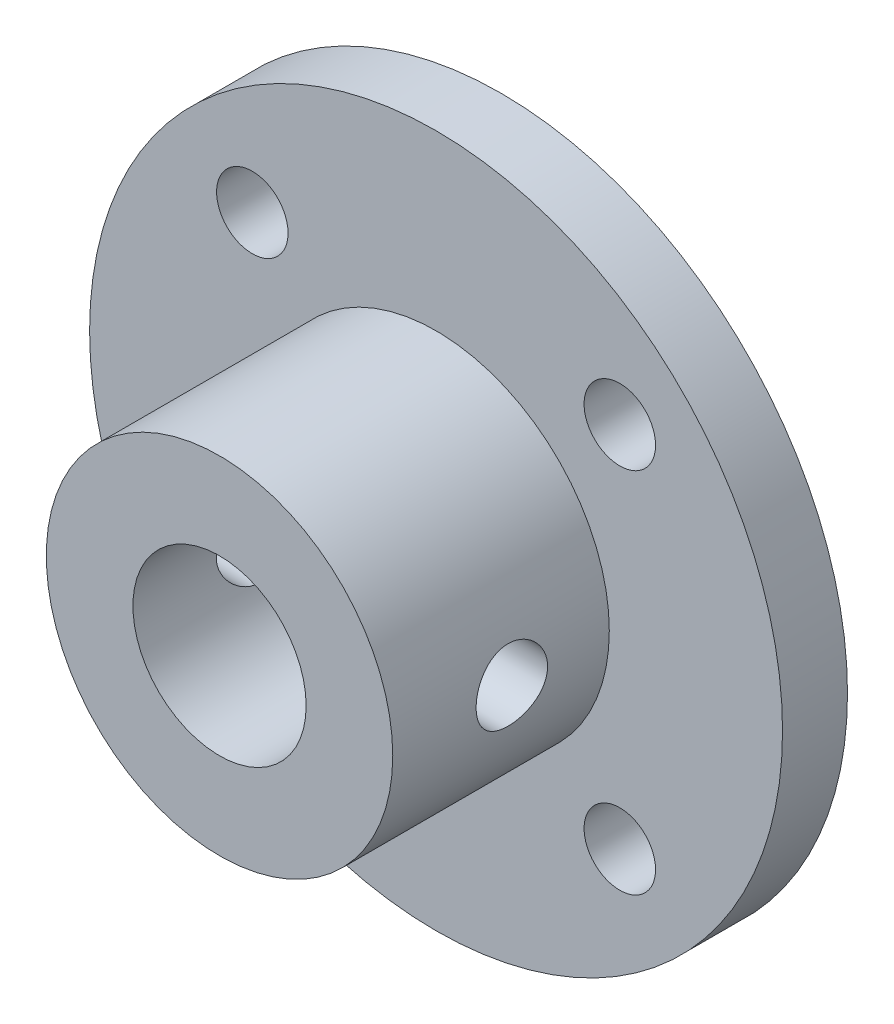
from build123d import *

# Parameters (mm, degrees)
SKETCH_1_R             = 16
EXTRUDE_1_DEPTH        = 3
SKETCH_2_R             = 8
EXTRUDE_2_DEPTH        = 10
SKETCH_3_R             = 4
CUT_EXTRUDE_1_DEPTH    = 14
SKETCH_5_R             = 1.5
CUT_EXTRUDE_3_DEPTH    = 4
HOLE_WIZARD_M4_1_D     = 3.3
HOLE_WIZARD_M4_1_DEPTH = 3
HOLE_WIZARD_M4_2_D     = 3.3


with BuildPart() as part:
    # 草图1 → 凸台-拉伸1 (new body)
    with BuildSketch(Plane.XY):
        Circle(SKETCH_1_R)
    extrude(amount=EXTRUDE_1_DEPTH)

    # 草图2 → 凸台-拉伸2 (add)
    with BuildSketch(Plane.XY.offset(3)):
        Circle(SKETCH_2_R)
    extrude(amount=EXTRUDE_2_DEPTH)

    # 草图3 → 切除-拉伸1 (cut, through all)
    with BuildSketch(Plane.XY.offset(13)):
        Circle(SKETCH_3_R)
    extrude(amount=-CUT_EXTRUDE_1_DEPTH, mode=Mode.SUBTRACT)

    # 草图5 → 切除-拉伸3 (cut, through all)
    with BuildSketch(Plane.XY.offset(3)):
        with Locations((-8.485281374, -8.485281374)):
            Circle(SKETCH_5_R)
        with Locations((-8.485281374, 8.485281374)):
            Circle(SKETCH_5_R)
        with Locations((8.485281374, -8.485281374)):
            Circle(SKETCH_5_R)
        with Locations((8.485281374, 8.485281374)):
            Circle(SKETCH_5_R)
    extrude(amount=-CUT_EXTRUDE_3_DEPTH, mode=Mode.SUBTRACT)

    # M4 螺纹孔1
    with Locations(Plane(origin=(-8.485281374, 8.485281374, 3), x_dir=(1, 0, 0), z_dir=(0, 0, 1))):
        with Locations((0, 0), (16.970562748, 0), (16.970562748, -16.970562748), (0, -16.970562748)):
            Hole(HOLE_WIZARD_M4_1_D / 2, depth=HOLE_WIZARD_M4_1_DEPTH)

    # M4 螺纹孔2 (through all)
    with Locations(Plane(origin=(8, 0, 7.5), x_dir=(0, 1, 0), z_dir=(1, 0, 0))):
        with Locations((0, 0)):
            Hole(HOLE_WIZARD_M4_2_D / 2)


solid = part.part
